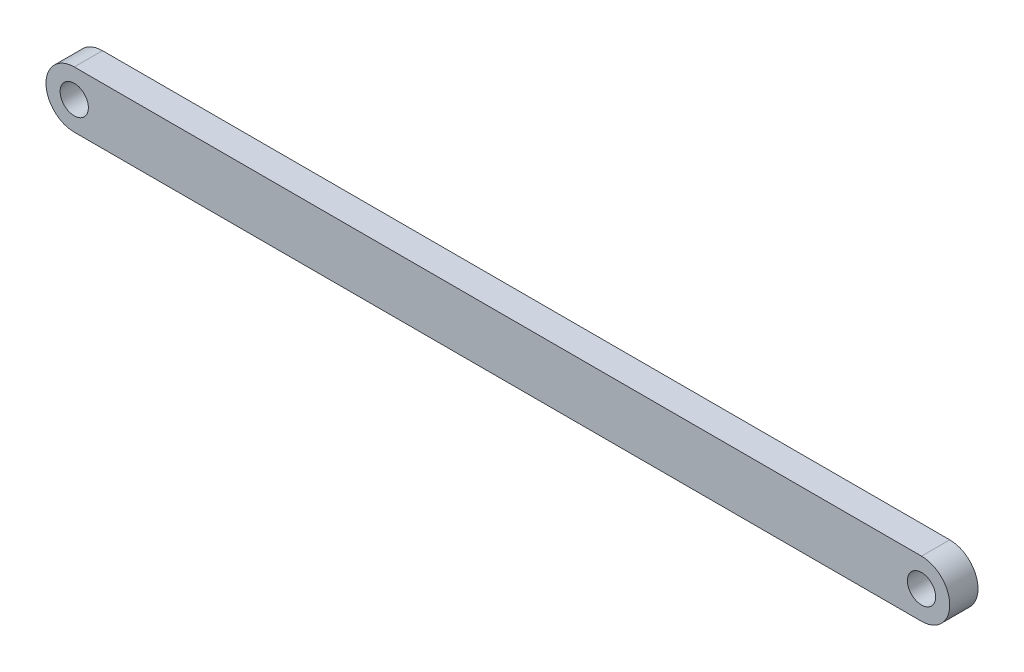
from build123d import *

# Parameters (mm, degrees)
SKETCH1_R           = 2.5
BOSS_EXTRUDE1_DEPTH = 5


with BuildPart() as part:
    # Sketch1 → Boss-Extrude1 (new body)
    with BuildSketch(Plane.XY):
        with BuildLine():
            Line((-75, 5), (75, 5))
            ThreePointArc((75, 5), (80, 0), (75, -5))
            Line((75, -5), (-75, -5))
            ThreePointArc((-75, -5), (-80, 0), (-75, 5))
        make_face()
        with Locations((-75, 0)):
            Circle(SKETCH1_R, mode=Mode.SUBTRACT)
        with Locations((75, 0)):
            Circle(SKETCH1_R, mode=Mode.SUBTRACT)
    extrude(amount=BOSS_EXTRUDE1_DEPTH)


solid = part.part
